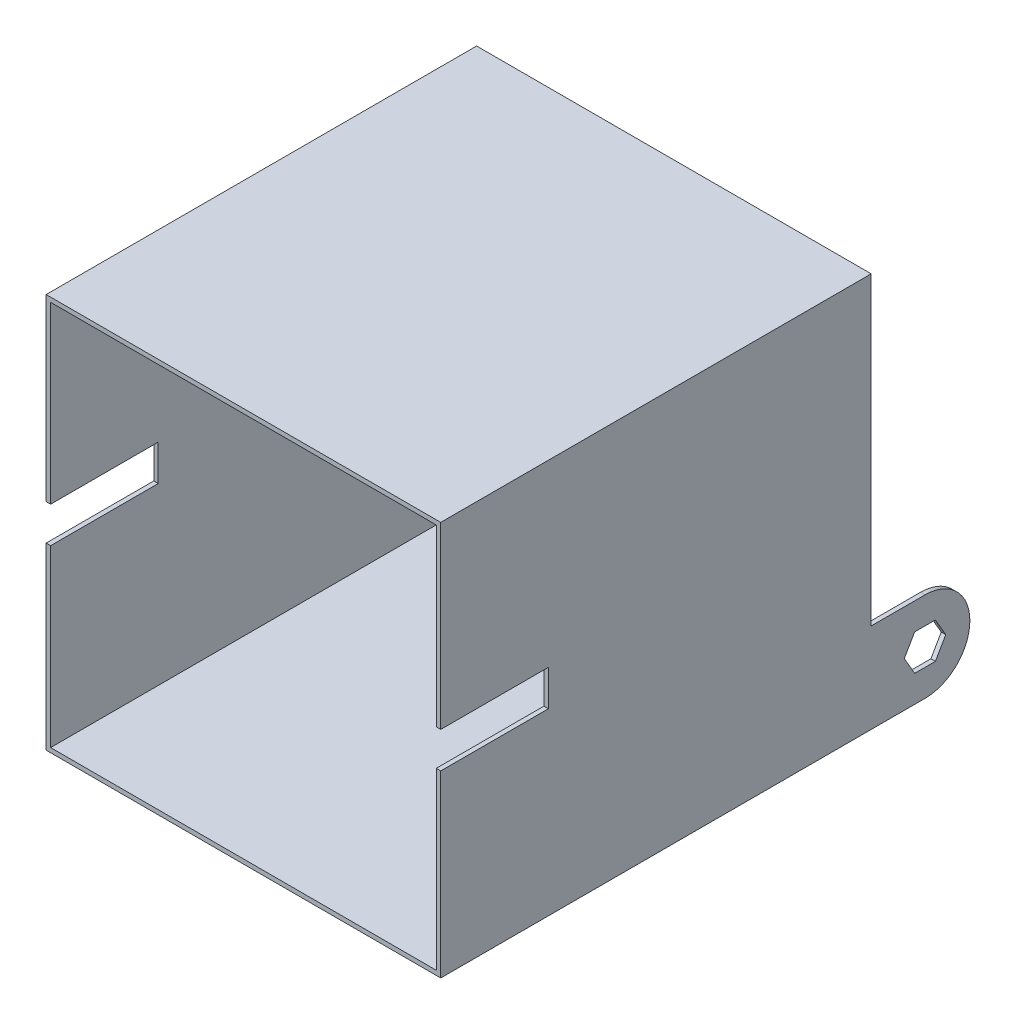
from build123d import *

# Parameters (mm, degrees)
SKETCH2_W           = 279.4
SKETCH2_H           = 279.4
BOSS_EXTRUDE2_DEPTH = 304.8
SHELL2_T            = -3.175
SKETCH4_W           = 76.2
SKETCH4_H           = 25.4
CUT_EXTRUDE2_DEPTH  = 280.4
BOSS_EXTRUDE5_DEPTH = 3.175
SKETCH6_R           = 12.7
CUT_EXTRUDE3_DEPTH  = 305.8


with BuildPart() as part:
    # Sketch2 → Boss-Extrude2 (new body)
    with BuildSketch(Plane.XY):
        with Locations((139.7, 139.7)):
            Rectangle(SKETCH2_W, SKETCH2_H)
    extrude(amount=BOSS_EXTRUDE2_DEPTH)

    # Shell2
    shell2_openings = [part.faces().sort_by_distance(p)[0] for p in [
        (139.7, 139.7, 304.8),
    ]]
    offset(amount=SHELL2_T, openings=shell2_openings, kind=Kind.INTERSECTION)

    # Sketch4 → Cut-Extrude2 (cut, through all)
    with BuildSketch(Plane.ZY):
        with Locations((266.7, 139.7)):
            Rectangle(SKETCH4_W, SKETCH4_H)
    extrude(amount=-CUT_EXTRUDE2_DEPTH, mode=Mode.SUBTRACT)

    # Sketch5 → Boss-Extrude5 (add)
    with BuildSketch(Plane(origin=(279.4, 0, 0), x_dir=(0, 0, -1), z_dir=(1, 0, 0))):
        Polygon((0, 63.5), (0, 0), (38.1, 0), (38.1, 19.05), (30.767651581, 19.05), (23.435303163, 31.75), (30.767651581, 44.45), (38.1, 44.45), (38.1, 63.5), align=None)
        with BuildLine():
            Line((38.1, 19.05), (38.1, 0))
            ThreePointArc((38.1, 0), (69.85, 31.75), (38.1, 63.5))
            Line((38.1, 63.5), (38.1, 44.45))
            Line((38.1, 44.45), (45.432348419, 44.45))
            Line((45.432348419, 44.45), (52.764696837, 31.75))
            Line((52.764696837, 31.75), (45.432348419, 19.05))
            Line((45.432348419, 19.05), (38.1, 19.05))
        make_face()
    boss_extrude5 = extrude(amount=-BOSS_EXTRUDE5_DEPTH)

    # Mirror1: Boss-Extrude5 across plane
    add(boss_extrude5.mirror(Plane(origin=(139.7, 0, 0), x_dir=(0, 0, 1), z_dir=(1, 0, 0))))

    # Sketch6 → Cut-Extrude3 (cut, through all)
    with BuildSketch(Plane(origin=(0, 0, 0), x_dir=(-1, 0, 0), z_dir=(0, 0, -1))):
        with Locations((-139.7, 139.7)):
            Circle(SKETCH6_R)
    extrude(amount=-CUT_EXTRUDE3_DEPTH, mode=Mode.SUBTRACT)


solid = part.part
